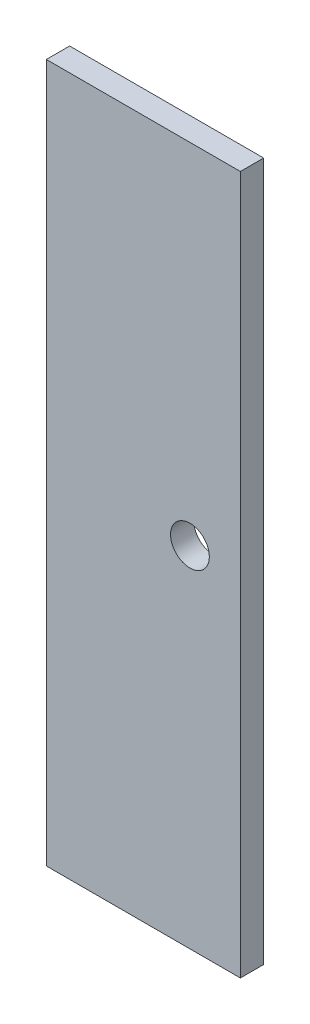
from build123d import *

# Parameters (mm, degrees)
CROQUIS1_W              = 50
CROQUIS1_H              = 180
SALIENTE_EXTRUIR1_DEPTH = 6
CROQUIS2_R              = 5
CORTAR_EXTRUIR1_DEPTH   = 10


with BuildPart() as part:
    # Croquis1 → Saliente-Extruir1 (new body)
    with BuildSketch(Plane.XY):
        Rectangle(CROQUIS1_W, CROQUIS1_H)
    extrude(amount=SALIENTE_EXTRUIR1_DEPTH)

    # Croquis2 → Cortar-Extruir1 (cut)
    with BuildSketch(Plane.XY.offset(6)):
        with Locations((12, 0)):
            Circle(CROQUIS2_R)
    extrude(amount=-CORTAR_EXTRUIR1_DEPTH, mode=Mode.SUBTRACT)


solid = part.part
